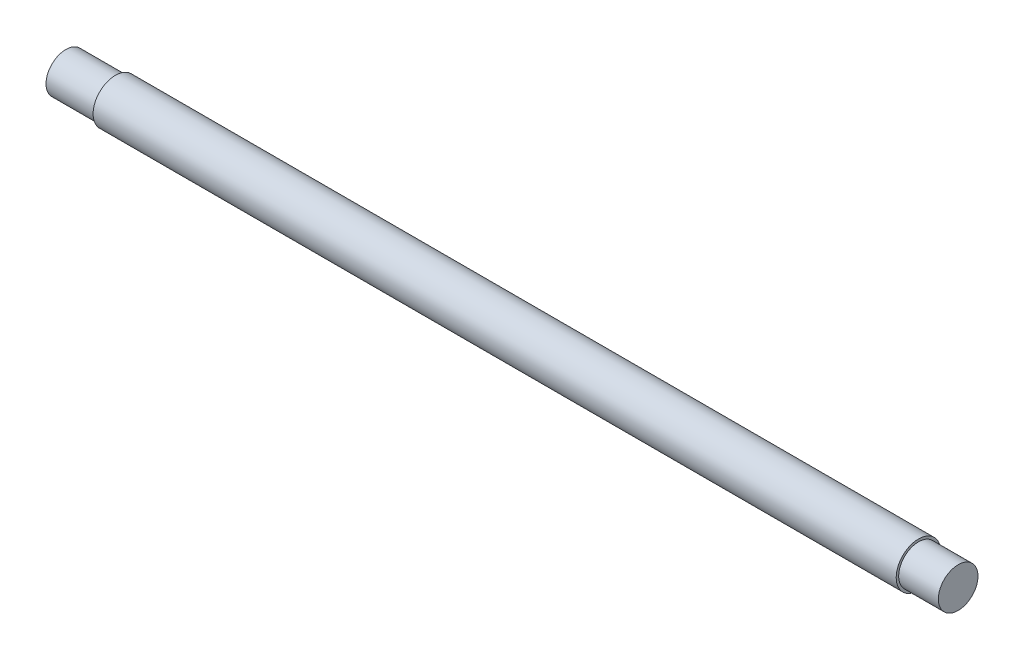
from build123d import *

# Parameters (mm, degrees)
SKETCH1_R           = 2.25
BOSS_EXTRUDE1_DEPTH = 45
SKETCH2_R           = 2.25
SKETCH2_R_2         = 2
CUT_EXTRUDE1_DEPTH  = 4
SKETCH3_R           = 2.25
SKETCH3_R_2         = 2
CUT_EXTRUDE2_DEPTH  = 5


with BuildPart() as part:
    # Sketch1 → Boss-Extrude1 (new body, symmetric)
    with BuildSketch(Plane(origin=(0, 0, 0), x_dir=(0, 0, -1), z_dir=(1, 0, 0))):
        Circle(SKETCH1_R)
    extrude(amount=BOSS_EXTRUDE1_DEPTH, both=True)

    # Sketch2 → Cut-Extrude1 (cut)
    with BuildSketch(Plane(origin=(45, 0, 0), x_dir=(0, 0, -1), z_dir=(1, 0, 0))):
        Circle(SKETCH2_R)
        Circle(SKETCH2_R_2, mode=Mode.SUBTRACT)
    extrude(amount=-CUT_EXTRUDE1_DEPTH, mode=Mode.SUBTRACT)

    # Sketch3 → Cut-Extrude2 (cut)
    with BuildSketch(Plane.ZY.offset(45)):
        Circle(SKETCH3_R)
        Circle(SKETCH3_R_2, mode=Mode.SUBTRACT)
    extrude(amount=-CUT_EXTRUDE2_DEPTH, mode=Mode.SUBTRACT)


solid = part.part
